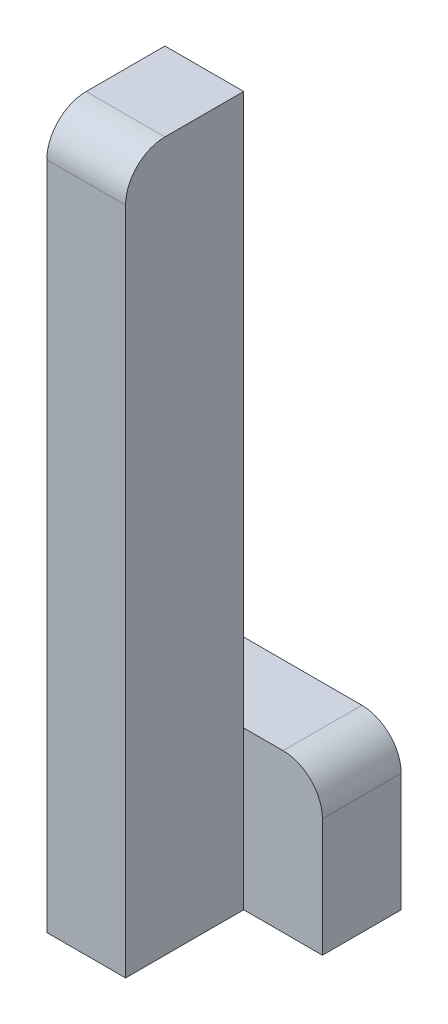
from build123d import *

# Parameters (mm, degrees)
SKETCH1_W           = 20
SKETCH1_H           = 180
BOSS_EXTRUDE1_DEPTH = 30
SKETCH2_W           = 40
SKETCH2_H           = 40
BOSS_EXTRUDE2_DEPTH = 20
FILLET1_R           = 10


with BuildPart() as part:
    # Sketch1 → Boss-Extrude1 (new body)
    with BuildSketch(Plane.XY):
        with Locations((-20, -90)):
            Rectangle(SKETCH1_W, SKETCH1_H)
    extrude(amount=BOSS_EXTRUDE1_DEPTH)

    # Sketch2 → Boss-Extrude2 (add)
    with BuildSketch(Plane.XY):
        with Locations((-10, -160)):
            Rectangle(SKETCH2_W, SKETCH2_H)
    extrude(amount=-BOSS_EXTRUDE2_DEPTH)

    # Fillet1
    fillet1_edges = [part.edges().sort_by_distance(p)[0] for p in [
        (10, -140, -10),
        (-20, 0, 30),
    ]]
    fillet(fillet1_edges, radius=FILLET1_R)


solid = part.part
